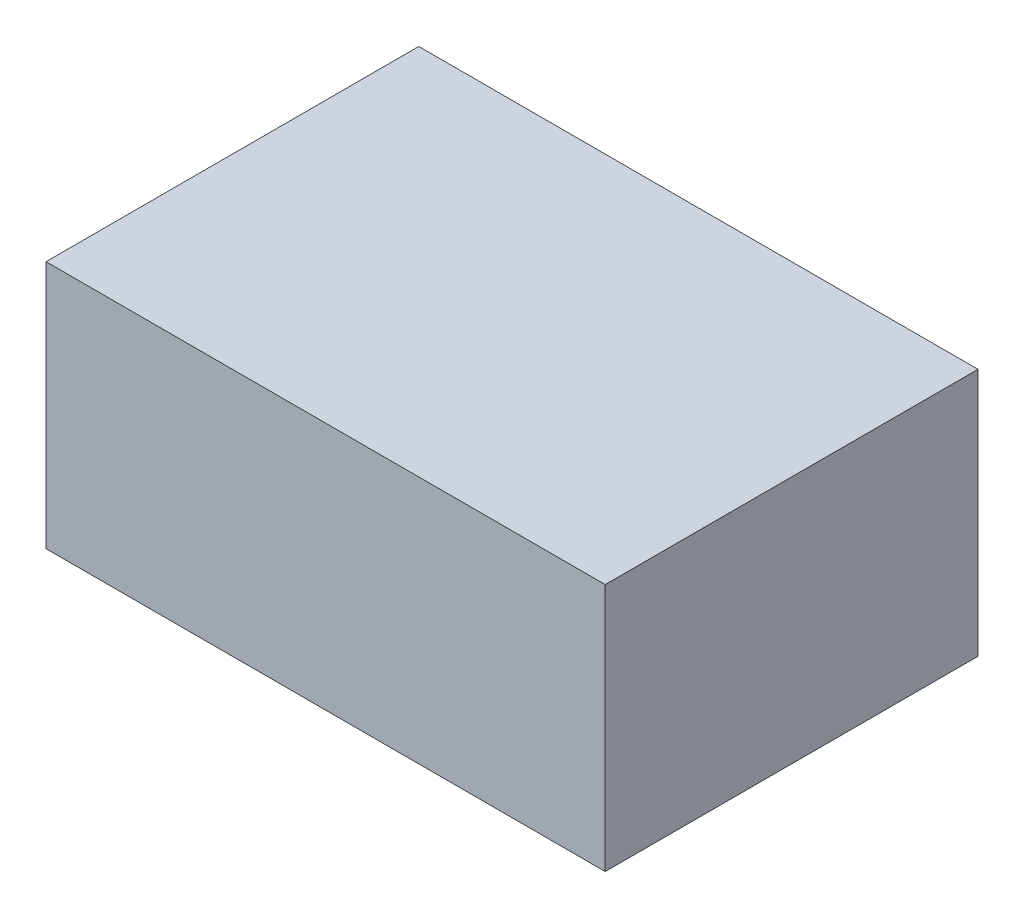
from build123d import *

# Parameters (mm, degrees)
SKETCH1_W           = 90
SKETCH1_H           = 60
BOSS_EXTRUDE2_DEPTH = 40
SKETCH3_R           = 1.6
CUT_EXTRUDE1_DEPTH  = 10


with BuildPart() as part:
    # Sketch1 → Boss-Extrude2 (new body)
    with BuildSketch(Plane(origin=(0, 0, 0), x_dir=(1, 0, 0), z_dir=(0, 1, 0))):
        Rectangle(SKETCH1_W, SKETCH1_H)
    extrude(amount=BOSS_EXTRUDE2_DEPTH)

    # Sketch3 → Cut-Extrude1 (cut)
    with BuildSketch(Plane(origin=(0, 0, 0), x_dir=(-1, 0, 0), z_dir=(0, -1, 0))):
        with Locations((40, -21.5)):
            Circle(SKETCH3_R)
        with Locations((-40, -21.5)):
            Circle(SKETCH3_R)
        with Locations((-40, 21.5)):
            Circle(SKETCH3_R)
        with Locations((40, 21.5)):
            Circle(SKETCH3_R)
    extrude(amount=-CUT_EXTRUDE1_DEPTH, mode=Mode.SUBTRACT)


solid = part.part
